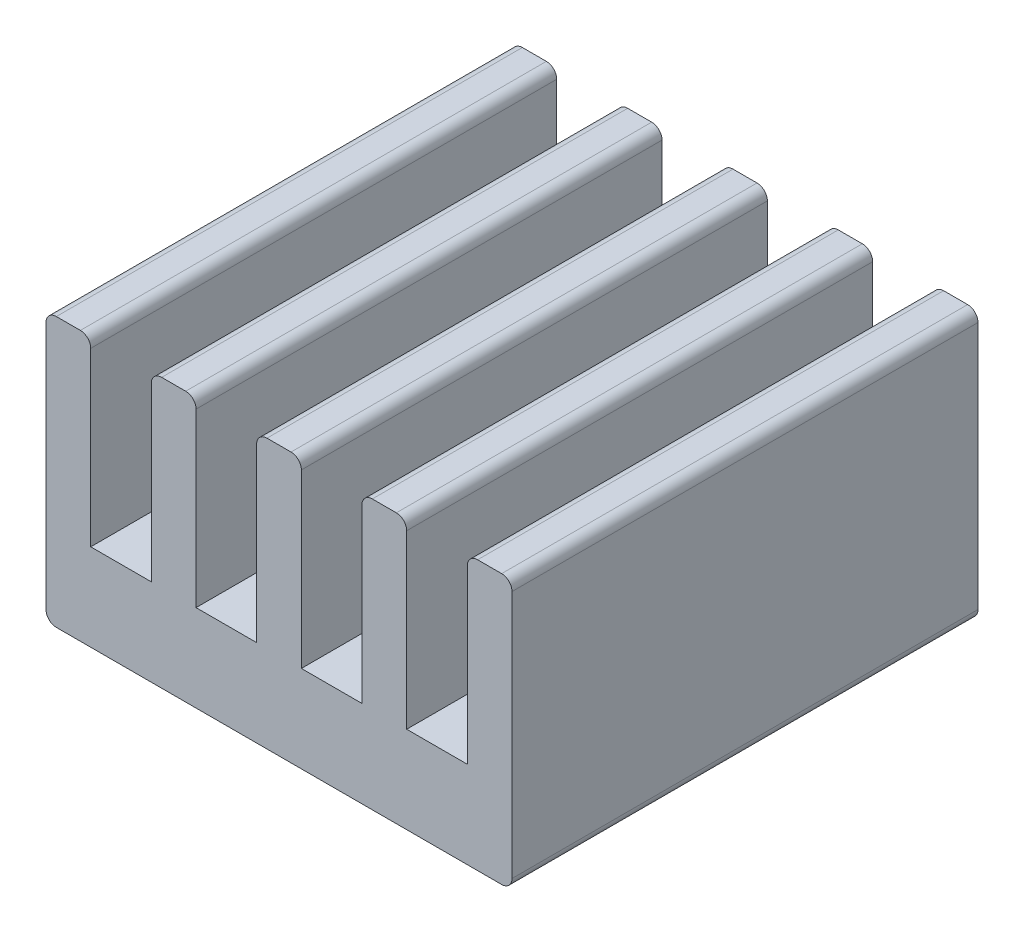
from build123d import *

# Parameters (mm, degrees)
SCHIZZO1_W                   = 9
SCHIZZO1_H                   = 9
ESTRUSIONE_ESTRUSIONE1_DEPTH = 5.2
SCHIZZO2_W                   = 1.17
SCHIZZO2_H                   = 3.52
TAGLIO_ESTRUSIONE1_DEPTH     = 10
RACCORDO1_R                  = 0.2


with BuildPart() as part:
    # Schizzo1 → Estrusione-Estrusione1 (new body)
    with BuildSketch(Plane(origin=(0, 0, 0), x_dir=(1, 0, 0), z_dir=(0, 1, 0))):
        Rectangle(SCHIZZO1_W, SCHIZZO1_H)
    extrude(amount=ESTRUSIONE_ESTRUSIONE1_DEPTH)

    # Schizzo2 → Taglio-Estrusione1 (cut, through all)
    with BuildSketch(Plane.XY.offset(4.5)):
        with Locations((-3.051, 3.44)):
            Rectangle(SCHIZZO2_W, SCHIZZO2_H)
        with Locations((1.017, 3.44)):
            Rectangle(SCHIZZO2_W, SCHIZZO2_H)
        with Locations((3.051, 3.44)):
            Rectangle(SCHIZZO2_W, SCHIZZO2_H)
        with Locations((-1.017, 3.44)):
            Rectangle(SCHIZZO2_W, SCHIZZO2_H)
    extrude(amount=-TAGLIO_ESTRUSIONE1_DEPTH, mode=Mode.SUBTRACT)

    # Raccordo1
    raccordo1_edges = [part.edges().sort_by_distance(p)[0] for p in [
        (-4.5, 5.2, 0),
        (-3.636, 5.2, 0),
        (-2.466, 5.2, 0),
        (0.432, 5.2, 0),
        (1.602, 5.2, 0),
        (4.5, 5.2, 0),
        (2.466, 5.2, 0),
        (3.636, 5.2, 0),
        (-4.5, 0, 0),
        (4.5, 0, 0),
        (-1.602, 5.2, 0),
        (-0.432, 5.2, 0),
    ]]
    fillet(raccordo1_edges, radius=RACCORDO1_R)


solid = part.part
